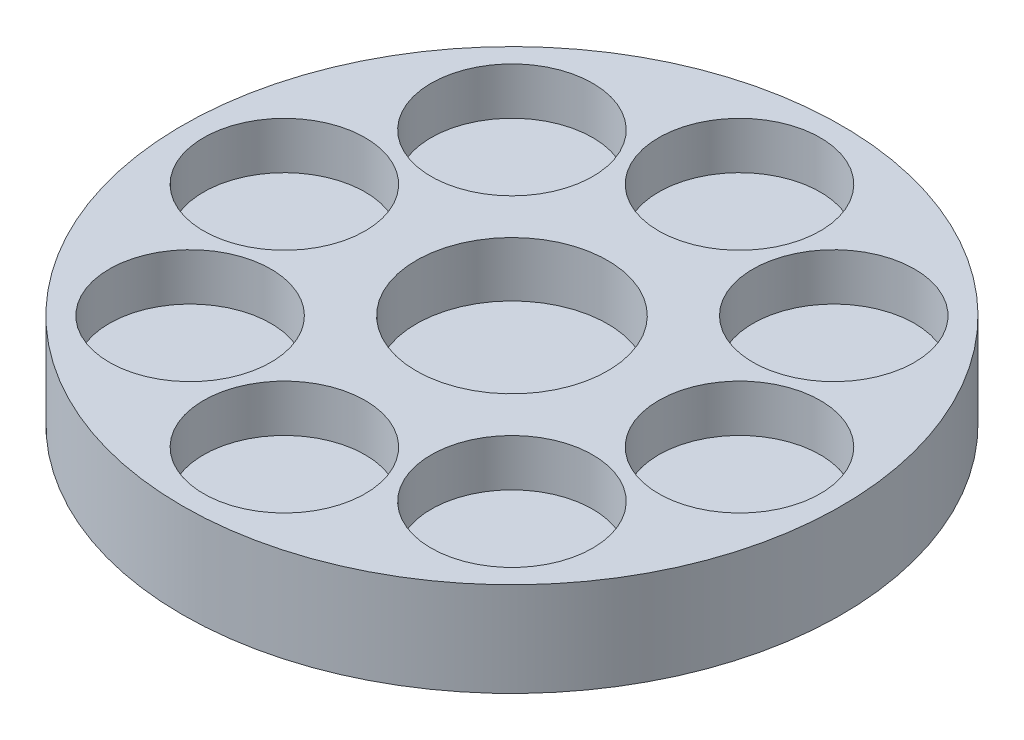
from build123d import *

# Parameters (mm, degrees)
SKETCH_1_R               = 21
EXTRUDE_9_DEPTH          = 6
SKETCH_2_R               = 5.15
CUT_EXTRUDE_11_DEPTH     = 3
PATTERN_CIRCULAR_4_COUNT = 8
CUT_EXTRUDE_12_DEPTH     = 1
SKETCH_4_R               = 6.1
CUT_EXTRUDE_13_DEPTH     = 3.5
SKETCH_5_R               = 3.15
SKETCH_5_R_2             = 1.95
CUT_EXTRUDE_14_DEPTH     = 1
SKETCH_6_R               = 4.15
SKETCH_6_R_2             = 3.15
EXTRUDE_10_DEPTH         = 5


with BuildPart() as part:
    # 스케치1 → 보스-돌출9 (new body)
    with BuildSketch(Plane(origin=(0, 0, 0), x_dir=(1, 0, 0), z_dir=(0, 1, 0))):
        Circle(SKETCH_1_R)
    extrude(amount=-EXTRUDE_9_DEPTH)

    # 스케치2 → 컷-돌출11 (cut)
    with BuildSketch(Plane(origin=(0, 0, 0), x_dir=(1, 0, 0), z_dir=(0, 1, 0))):
        with Locations((0, 14.5)):
            Circle(SKETCH_2_R)
    cut_extrude_11 = extrude(amount=-CUT_EXTRUDE_11_DEPTH, mode=Mode.SUBTRACT)

    # 원형 패턴4: 컷-돌출11 ×8 about axis
    pattern_circular_4_axis = Axis((0, 0, 0), (0, 1, 0))
    for i in range(1, PATTERN_CIRCULAR_4_COUNT):
        add(cut_extrude_11.rotate(pattern_circular_4_axis, i * 360 / PATTERN_CIRCULAR_4_COUNT), mode=Mode.SUBTRACT)

    # 스케치3 → 컷-돌출12 (cut)
    with BuildSketch(Plane.XZ.offset(6)):
        Polygon((-14.320132754, -5.931593202), (-5.931593202, -14.320132754), (5.931593202, -14.320132754), (14.320132754, -5.931593202), (14.320132754, 5.931593202), (5.931593202, 14.320132754), (-5.931593202, 14.320132754), (-14.320132754, 5.931593202), align=None)
        Polygon((-5.434536927, -13.120132754), (5.434536927, -13.120132754), (13.120132754, -5.434536927), (13.120132754, 5.434536927), (5.434536927, 13.120132754), (-5.434536927, 13.120132754), (-13.120132754, 5.434536927), (-13.120132754, -5.434536927), align=None, mode=Mode.SUBTRACT)
    extrude(amount=-CUT_EXTRUDE_12_DEPTH, mode=Mode.SUBTRACT)

    # 스케치4 → 컷-돌출13 (cut)
    with BuildSketch(Plane(origin=(0, 0, 0), x_dir=(1, 0, 0), z_dir=(0, 1, 0))):
        Circle(SKETCH_4_R)
    extrude(amount=-CUT_EXTRUDE_13_DEPTH, mode=Mode.SUBTRACT)

    # 스케치5 → 컷-돌출14 (cut)
    with BuildSketch(Plane.XZ.offset(6)):
        Circle(SKETCH_5_R)
        Circle(SKETCH_5_R_2, mode=Mode.SUBTRACT)
    extrude(amount=-CUT_EXTRUDE_14_DEPTH, mode=Mode.SUBTRACT)

    # 스케치6 → 보스-돌출10 (add)
    with BuildSketch(Plane.XZ.offset(6)):
        Circle(SKETCH_6_R)
        Circle(SKETCH_6_R_2, mode=Mode.SUBTRACT)
    extrude(amount=EXTRUDE_10_DEPTH)


solid = part.part
